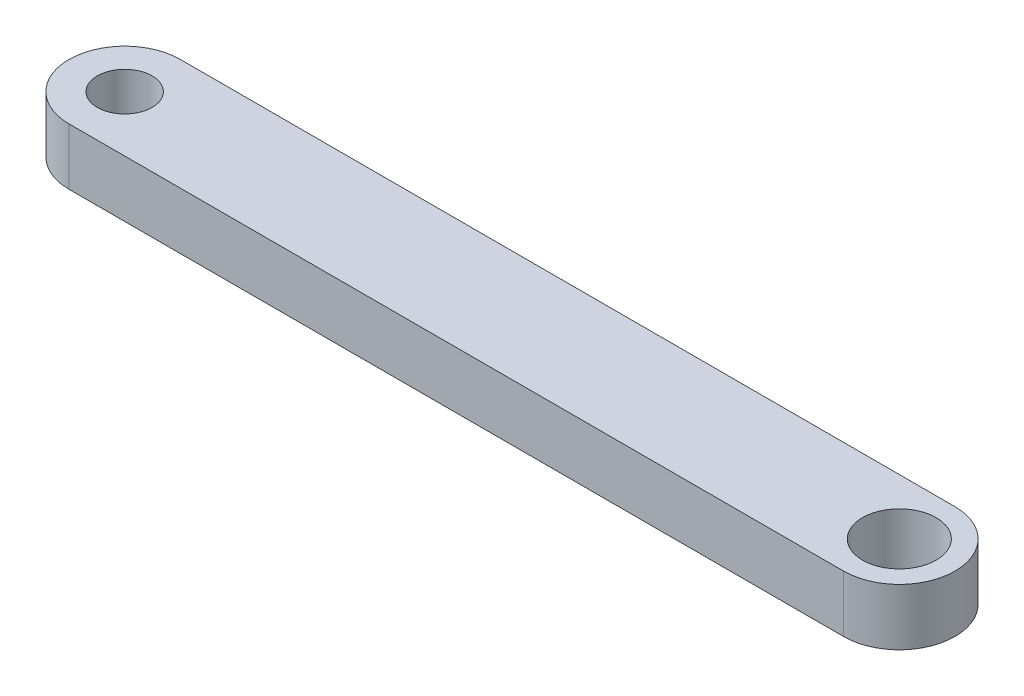
from build123d import *

# Parameters (mm, degrees)
SKETCH1_R           = 1.95
SKETCH1_R_2         = 1.45
BOSS_EXTRUDE1_DEPTH = 3


with BuildPart() as part:
    # Sketch1 → Boss-Extrude1 (new body)
    with BuildSketch(Plane.XZ):
        with BuildLine():
            Line((32, 2.95), (-9, 2.95))
            ThreePointArc((-9, 2.95), (-11.95, 0), (-9, -2.95))
            Line((-9, -2.95), (32, -2.95))
            ThreePointArc((32, -2.95), (34.95, 0), (32, 2.95))
        make_face()
        with Locations((32, 0)):
            Circle(SKETCH1_R, mode=Mode.SUBTRACT)
        with Locations((-9, 0)):
            Circle(SKETCH1_R_2, mode=Mode.SUBTRACT)
    extrude(amount=-BOSS_EXTRUDE1_DEPTH)


solid = part.part
